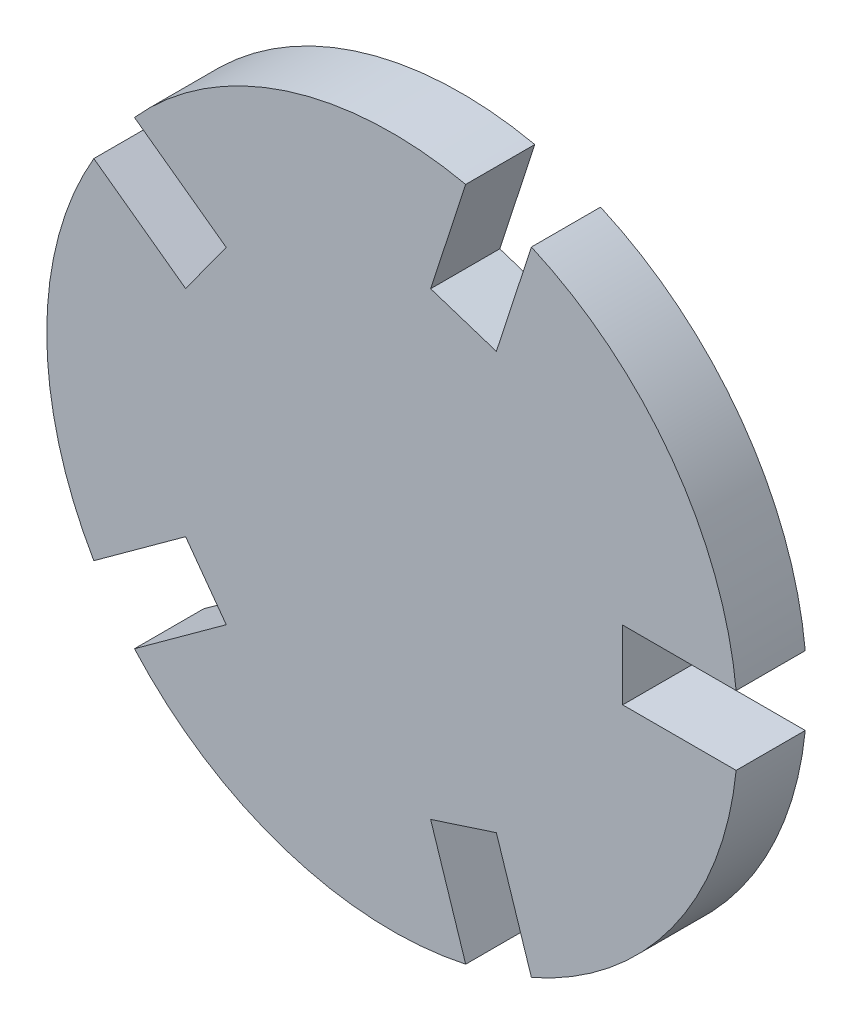
from build123d import *

# Parameters (mm, degrees)
SALIENTE_EXTRUIR1_DEPTH = 3


with BuildPart() as part:
    # Croquis1 → Saliente-Extruir1 (new body)
    with BuildSketch(Plane.XY):
        with BuildLine():
            Line((14.924811557, -1.5), (10, -1.5))
            Line((10, -1.5), (10, 1.5))
            Line((10, 1.5), (14.924811557, 1.5))
            ThreePointArc((14.924811557, 1.5), (12.135254916, 8.816778784), (6.038605183, 13.730813794))
            Line((6.038605183, 13.730813794), (4.516754718, 9.047039671))
            Line((4.516754718, 9.047039671), (1.663585169, 9.974090655))
            Line((1.663585169, 9.974090655), (3.185435634, 14.657864777))
            ThreePointArc((3.185435634, 14.657864777), (-4.635254916, 14.265847744), (-11.192748309, 9.986109618))
            Line((-11.192748309, 9.986109618), (-7.208492065, 7.091378014))
            Line((-7.208492065, 7.091378014), (-8.971847822, 4.664327031))
            Line((-8.971847822, 4.664327031), (-12.956104066, 7.559058635))
            ThreePointArc((-12.956104066, 7.559058635), (-15, 0), (-12.956104066, -7.559058635))
            Line((-12.956104066, -7.559058635), (-8.971847822, -4.664327031))
            Line((-8.971847822, -4.664327031), (-7.208492065, -7.091378014))
            Line((-7.208492065, -7.091378014), (-11.192748309, -9.986109618))
            ThreePointArc((-11.192748309, -9.986109618), (-4.635254916, -14.265847744), (3.185435634, -14.657864777))
            Line((3.185435634, -14.657864777), (1.663585169, -9.974090655))
            Line((1.663585169, -9.974090655), (4.516754718, -9.047039671))
            Line((4.516754718, -9.047039671), (6.038605183, -13.730813794))
            ThreePointArc((6.038605183, -13.730813794), (12.135254916, -8.816778784), (14.924811557, -1.5))
        make_face()
    extrude(amount=SALIENTE_EXTRUIR1_DEPTH)


solid = part.part
